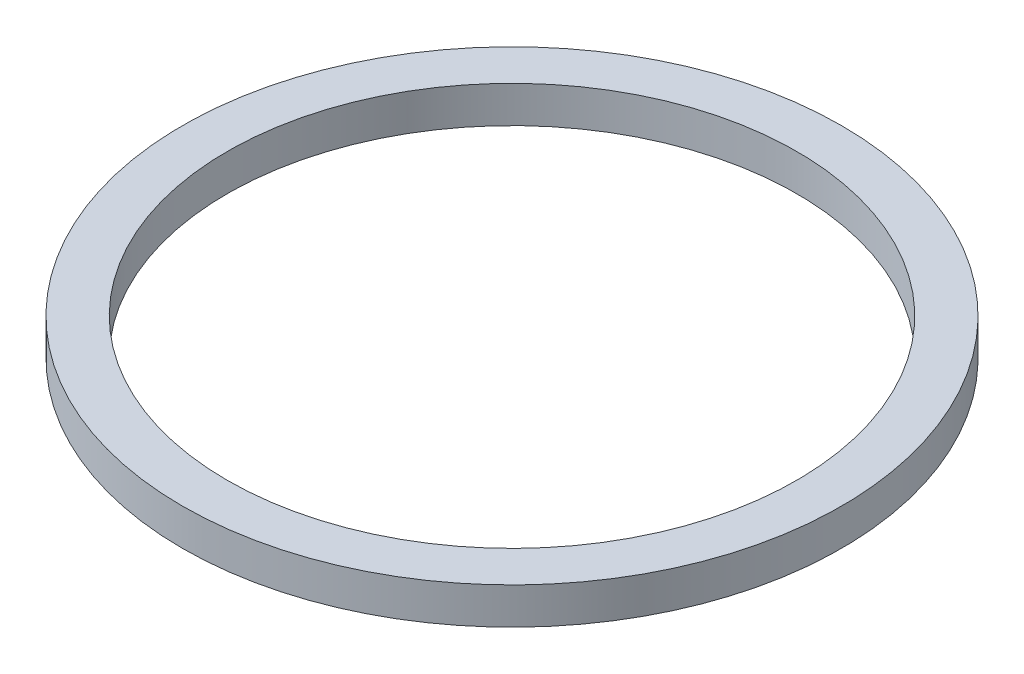
from build123d import *

# Parameters (mm, degrees)
SKETCH1_R           = 40.5
BOSS_EXTRUDE1_DEPTH = 4.5
SKETCH2_R           = 35
CUT_EXTRUDE1_DEPTH  = 5.5


with BuildPart() as part:
    # Sketch1 → Boss-Extrude1 (new body)
    with BuildSketch(Plane(origin=(0, 0, 0), x_dir=(1, 0, 0), z_dir=(0, 1, 0))):
        Circle(SKETCH1_R)
    extrude(amount=BOSS_EXTRUDE1_DEPTH)

    # Sketch2 → Cut-Extrude1 (cut, through all)
    with BuildSketch(Plane(origin=(0, 4.5, 0), x_dir=(1, 0, 0), z_dir=(0, 1, 0))):
        Circle(SKETCH2_R)
    extrude(amount=-CUT_EXTRUDE1_DEPTH, mode=Mode.SUBTRACT)


solid = part.part
